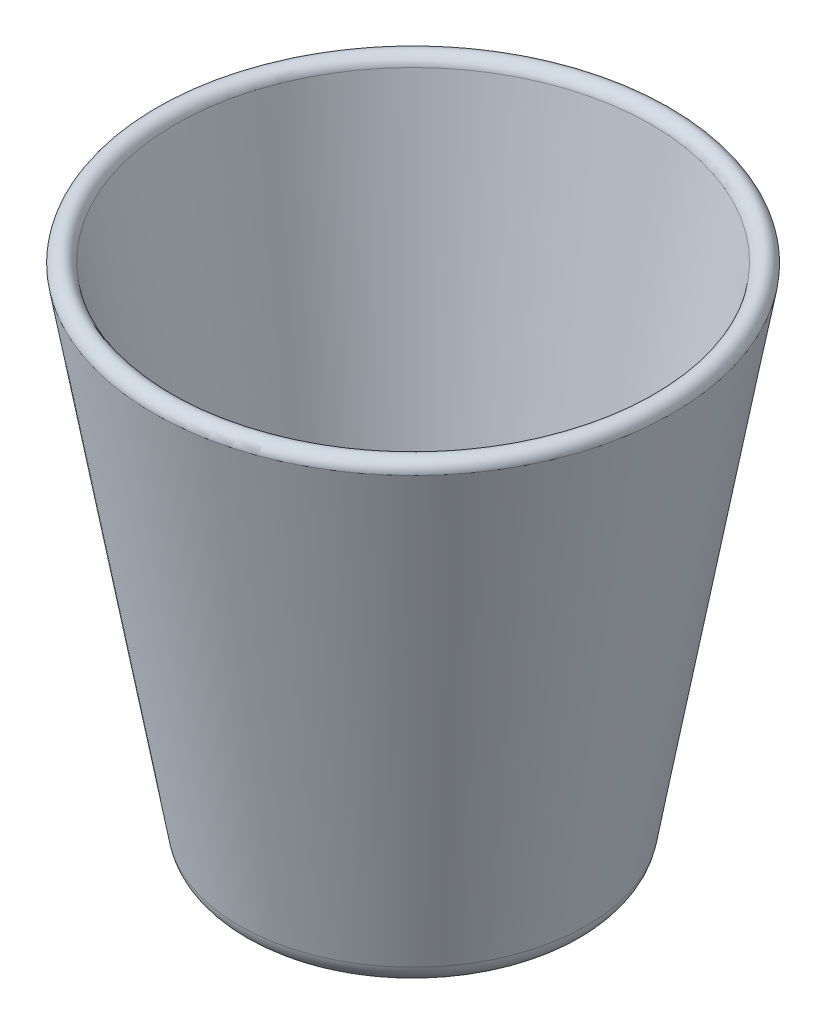
from build123d import *


with BuildPart() as part:
    # Sketch1 → Revolve1 (revolve)
    with BuildSketch(Plane.XY):
        with BuildLine():
            Line((0, 0), (66.209470016, 0))
            ThreePointArc((66.209470016, 0), (73.862659994, 2.785533349), (77.934837326, 9.838751385))
            Line((77.934837326, 9.838751385), (116.50834779, 228.6))
            ThreePointArc((116.50834779, 228.6), (112.127650699, 233.380691976), (106.98334779, 229.43332952))
            Line((106.98334779, 229.43332952), (68.554543478, 11.492750277))
            ThreePointArc((68.554543478, 11.492750277), (67.740108012, 10.08210667), (66.209470016, 9.525))
            Line((66.209470016, 9.525), (0, 9.525))
            Line((0, 9.525), (0, 0))
        make_face()
    revolve(axis=Axis((0, 0, 0), (0, 1, 0)))


solid = part.part
